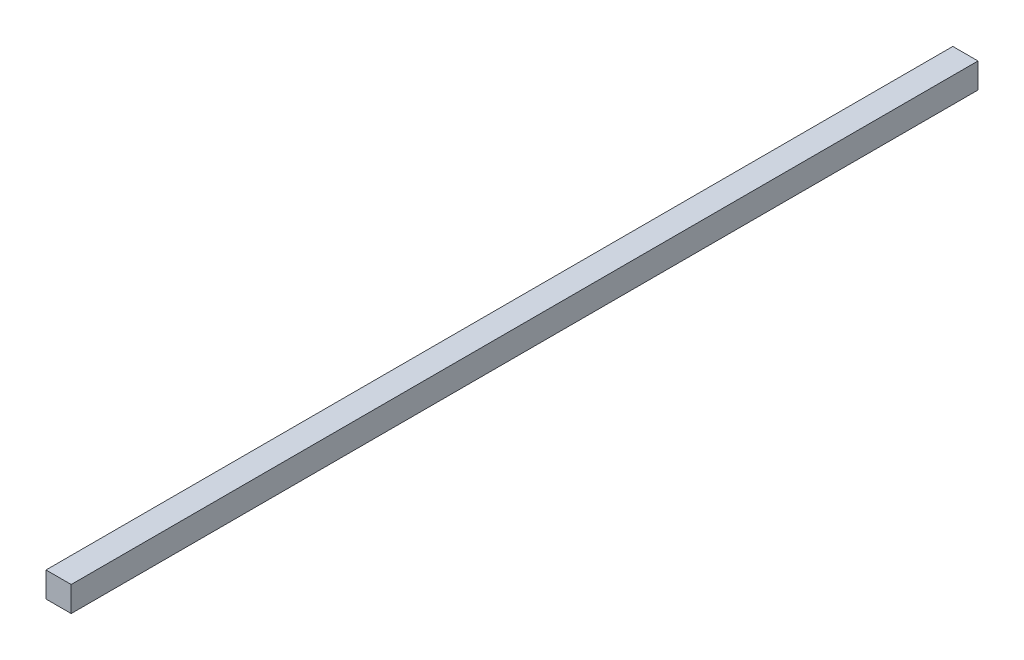
from build123d import *

# Parameters (mm, degrees)
SKETCH1_W          = 6.35
SKETCH1_H          = 6.35
EXTRUDE1_DEPTH     = 304.8
SKETCH2_W          = 76.2
SKETCH2_H          = 6.35
CUT_EXTRUDE1_DEPTH = 7.35


with BuildPart() as part:
    # Sketch1 → Extrude1 (new body)
    with BuildSketch(Plane.XY):
        Rectangle(SKETCH1_W, SKETCH1_H)
    extrude(amount=-EXTRUDE1_DEPTH)

    # Sketch2 → Cut-Extrude1 (cut, through all)
    with BuildSketch(Plane.ZY.offset(3.175)):
        with Locations((-266.7, 0)):
            Rectangle(SKETCH2_W, SKETCH2_H)
    extrude(amount=-CUT_EXTRUDE1_DEPTH, mode=Mode.SUBTRACT)


solid = part.part
